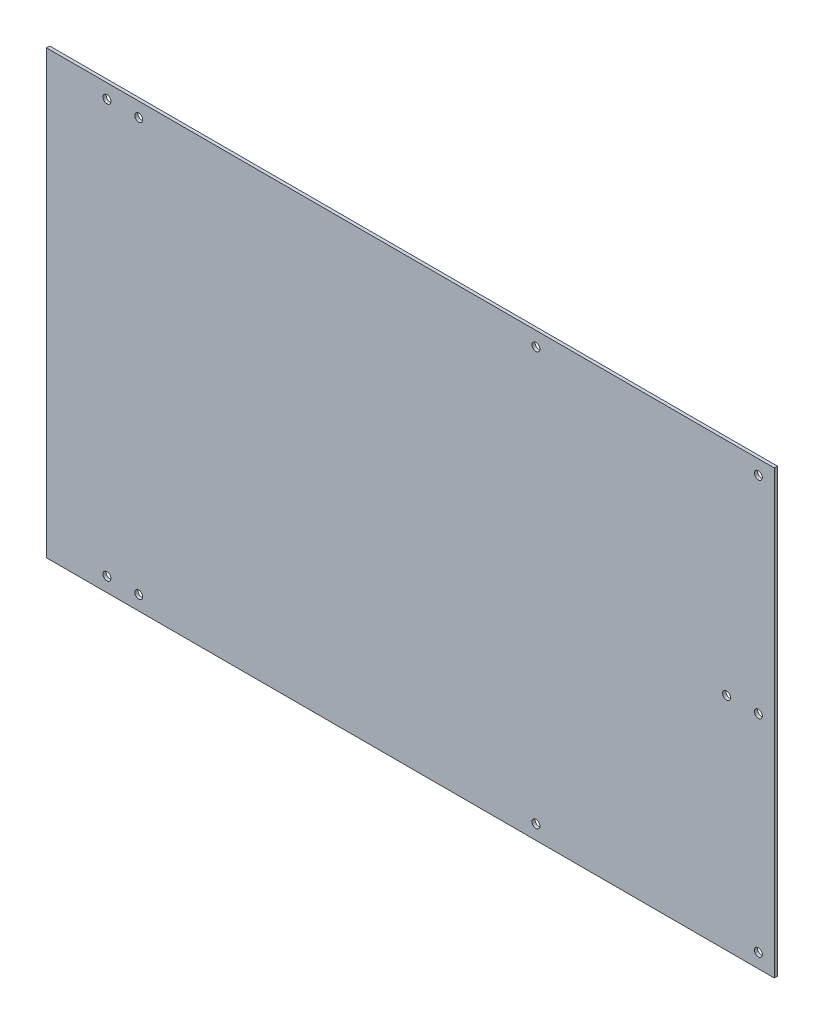
from build123d import *

# Parameters (mm, degrees)
SKETCH_1_W      = 458
SKETCH_1_H      = 278
SKETCH_1_R      = 2.5
EXTRUDE_1_DEPTH = 2


with BuildPart() as part:
    # 草图1 → 凸台-拉伸1 (new body)
    with BuildSketch(Plane.XY):
        with Locations((115.490809865, -96.636228994)):
            Rectangle(SKETCH_1_W, SKETCH_1_H)
        with Locations((334.490809865, -226.636228994)):
            Circle(SKETCH_1_R, mode=Mode.SUBTRACT)
        with Locations((194.490809865, -226.636228994)):
            Circle(SKETCH_1_R, mode=Mode.SUBTRACT)
        with Locations((194.490809865, 33.363771006)):
            Circle(SKETCH_1_R, mode=Mode.SUBTRACT)
        with Locations((334.490809865, 33.363771006)):
            Circle(SKETCH_1_R, mode=Mode.SUBTRACT)
        with Locations((-55.509190135, 33.363771006)):
            Circle(SKETCH_1_R, mode=Mode.SUBTRACT)
        with Locations((-75.509190135, 33.363771006)):
            Circle(SKETCH_1_R, mode=Mode.SUBTRACT)
        with Locations((-75.509190135, -226.636228994)):
            Circle(SKETCH_1_R, mode=Mode.SUBTRACT)
        with Locations((-55.509190135, -226.636228994)):
            Circle(SKETCH_1_R, mode=Mode.SUBTRACT)
        with Locations((334.490809865, -96.636228994)):
            Circle(SKETCH_1_R, mode=Mode.SUBTRACT)
        with Locations((314.490809865, -96.636228994)):
            Circle(SKETCH_1_R, mode=Mode.SUBTRACT)
    extrude(amount=EXTRUDE_1_DEPTH)


solid = part.part
